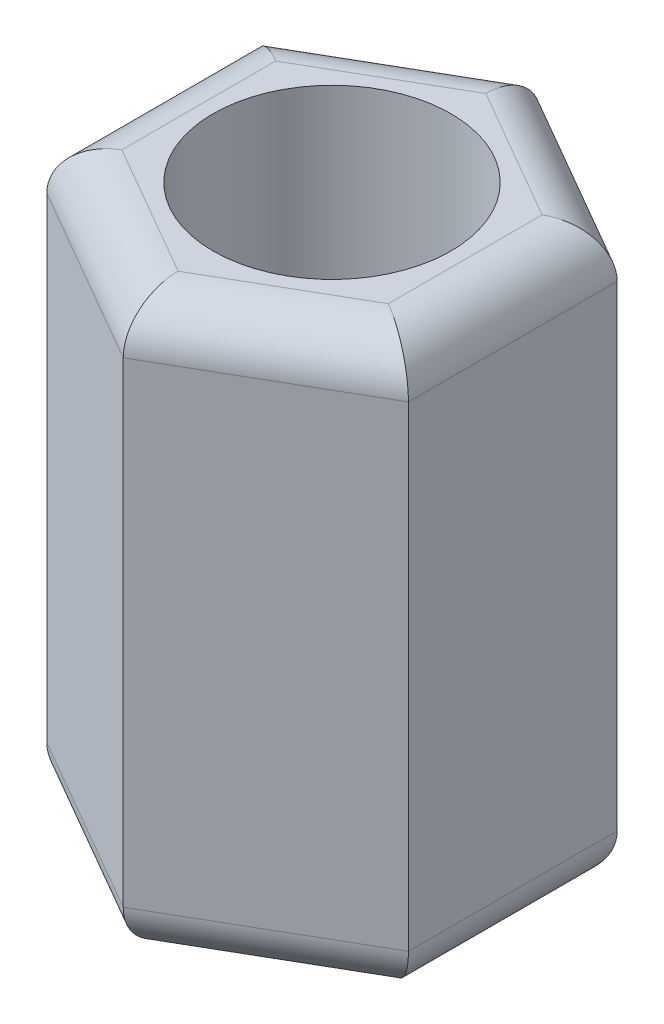
from build123d import *

# Parameters (mm, degrees)
SKETCH_1_R      = 1.25
EXTRUDE_1_DEPTH = 6
FILLET_1_R      = 0.5


with BuildPart() as part:
    # 草图1 → 凸台-拉伸1 (new body)
    with BuildSketch(Plane(origin=(0, 0, 0), x_dir=(1, 0, 0), z_dir=(0, 1, 0))):
        Polygon((1.9, -1.096965511), (1.9, 1.096965511), (0, 2.193931023), (-1.9, 1.096965511), (-1.9, -1.096965511), (0, -2.193931023), align=None)
        Circle(SKETCH_1_R, mode=Mode.SUBTRACT)
    extrude(amount=EXTRUDE_1_DEPTH)

    # 圆角1
    fillet_1_edges = [part.edges().sort_by_distance(p)[0] for p in [
        (0.95, 6, -1.645448267),
        (-0.95, 6, -1.645448267),
        (-1.9, 6, 0),
        (-0.95, 6, 1.645448267),
        (0.95, 6, 1.645448267),
        (-0.95, 0, 1.645448267),
        (-1.9, 0, 0),
        (-0.95, 0, -1.645448267),
        (0.95, 0, -1.645448267),
        (1.9, 0, 0),
        (0.95, 0, 1.645448267),
        (1.9, 6, 0),
    ]]
    fillet(fillet_1_edges, radius=FILLET_1_R)


solid = part.part
